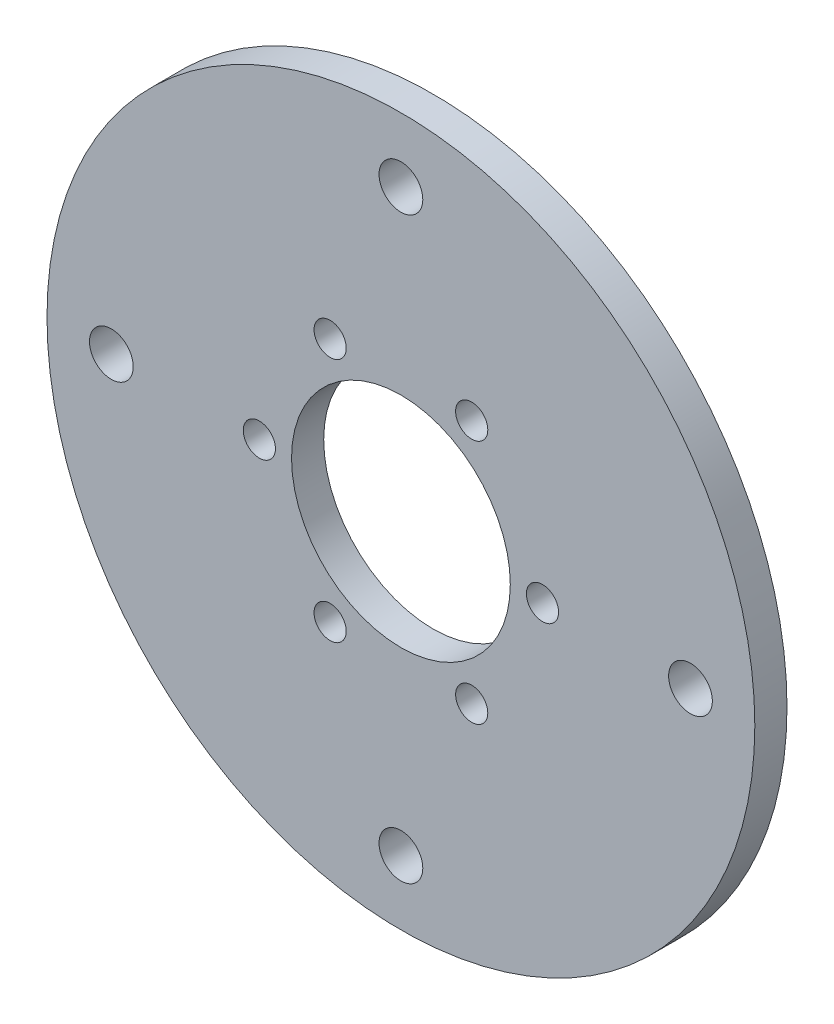
from build123d import *

# Parameters (mm, degrees)
ESQUISSE1_R                               = 55
ESQUISSE1_R_2                             = 17
BOSS_EXTRU_1_DEPTH                        = 5
TROU_POUR_TARAUDAGE_POUR_TROU_TARAUD_M8_D = 6.8
TROU_POUR_TARAUDAGE_POUR_TROU_TARAUD_M6_D = 5


with BuildPart() as part:
    # Esquisse1 → Boss.-Extru.1 (new body)
    with BuildSketch(Plane.XY):
        Circle(ESQUISSE1_R)
        Circle(ESQUISSE1_R_2, mode=Mode.SUBTRACT)
    extrude(amount=BOSS_EXTRU_1_DEPTH)

    # Trou pour taraudage pour trou taraudé M8x1.252 (through all)
    with Locations(Plane.XY.offset(5)):
        with Locations((0, 45), (45, 0), (0, -45), (-45, 0)):
            Hole(TROU_POUR_TARAUDAGE_POUR_TROU_TARAUD_M8_D / 2)

    # Trou pour taraudage pour trou taraudé M6x1.02 (through all)
    with Locations(Plane.XY.offset(5)):
        with Locations((11, 19.052558883), (22, 0), (11, -19.052558883), (-11, -19.052558883), (-22, 0), (-11, 19.052558883)):
            Hole(TROU_POUR_TARAUDAGE_POUR_TROU_TARAUD_M6_D / 2)


solid = part.part
